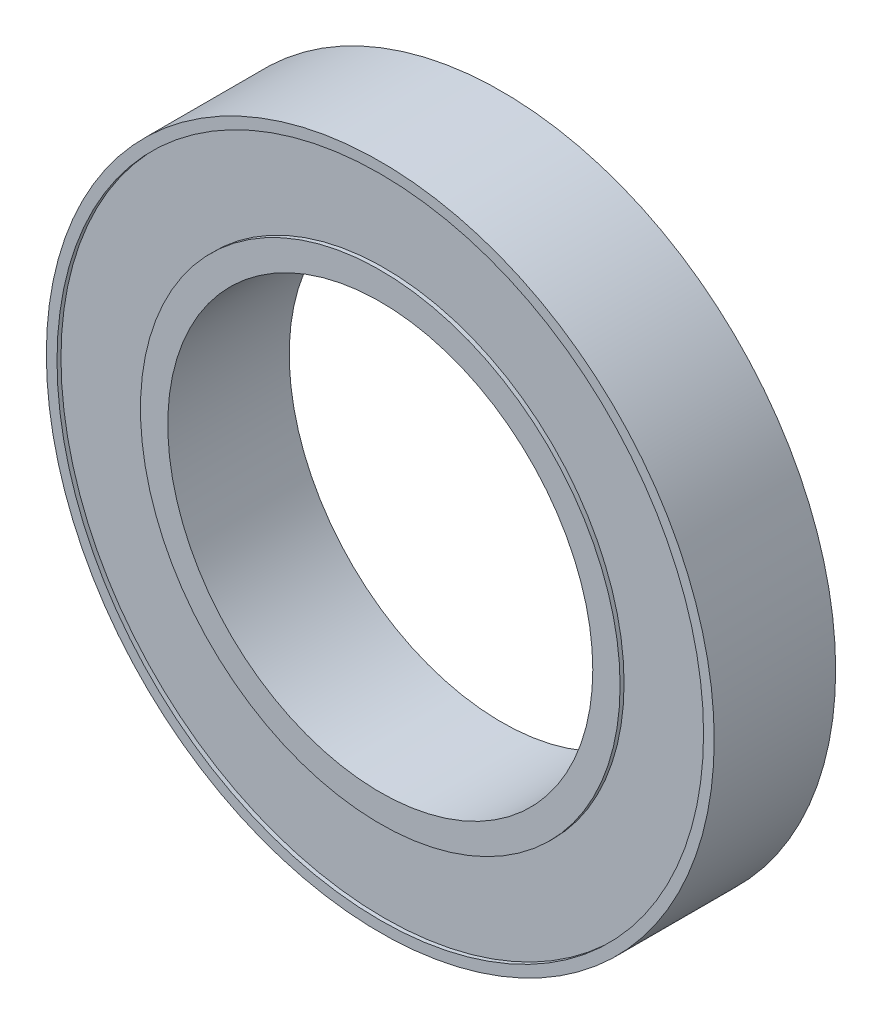
from build123d import *


with BuildPart() as part:
    # Sketch1 → Revolve1 (revolve)
    with BuildSketch(Plane(origin=(0, 0, 0), x_dir=(1, 0, 0), z_dir=(0, 1, 0))):
        Polygon((17.5, -5), (17.5, 5), (19.749072232, 5), (19.749072232, 4.672979423), (26.621019229, 4.672979423), (26.621019229, 5), (27.5, 5), (27.5, -5), (26.621019229, -5), (26.621019229, -4.672979423), (19.749072232, -4.672979423), (19.749072232, -5), align=None)
    revolve(axis=Axis((0, 0, 0), (0, 0, -1)))


solid = part.part
